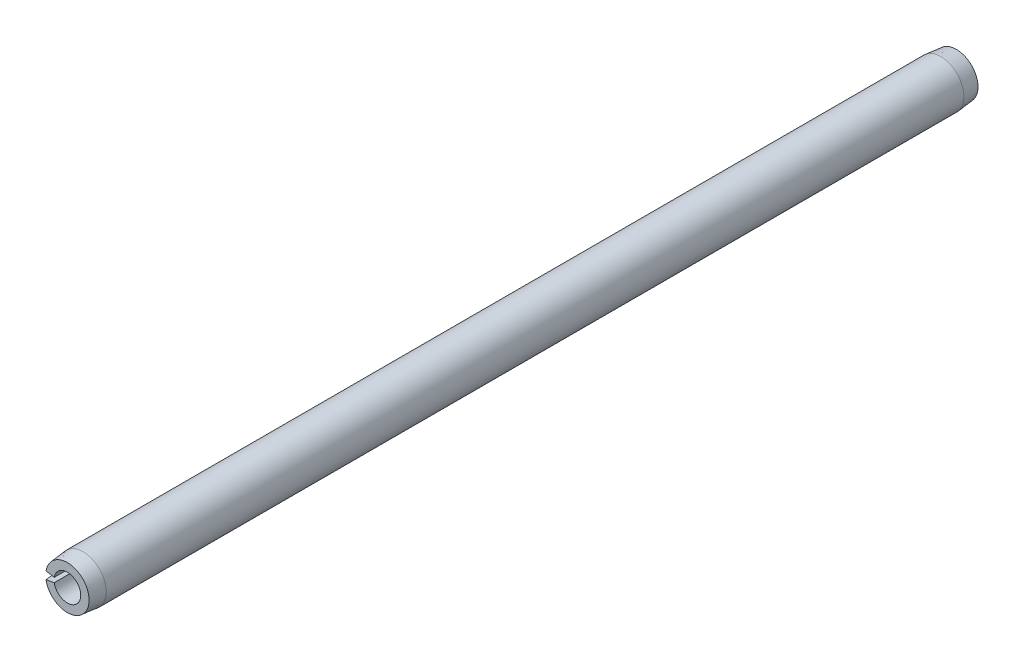
from build123d import *

# Parameters (mm, degrees)
EXTRUDE1_DEPTH = 31.75


with BuildPart() as part:
    # Sketch1 → Extrude1 (new body, symmetric)
    with BuildSketch(Plane.XY):
        with BuildLine():
            Line((-1.638424659, 0.288898473), (-0.938029385, 0.165399889))
            ThreePointArc((-0.938029385, 0.165399889), (0.9525, 0), (-0.938029385, -0.165399889))
            Line((-0.938029385, -0.165399889), (-1.638424659, -0.288898473))
            ThreePointArc((-1.638424659, -0.288898473), (1.6637, 0), (-1.638424659, 0.288898473))
        make_face()
    extrude(amount=EXTRUDE1_DEPTH, both=True)

    # Sketch2 → Cut-Revolve1 (revolve, cut)
    with BuildSketch(Plane(origin=(0, 0, 0), x_dir=(0, 0, -1), z_dir=(1, 0, 0))):
        Polygon((31.75, 1.6637), (31.75, 1.5494), (30.6324, 1.6637), align=None)
        Polygon((-30.6324, 1.6637), (-31.75, 1.6637), (-31.75, 1.5494), align=None)
    revolve(axis=Axis((0, 0, -31.75), (0, 0, 1)), mode=Mode.SUBTRACT)


solid = part.part
